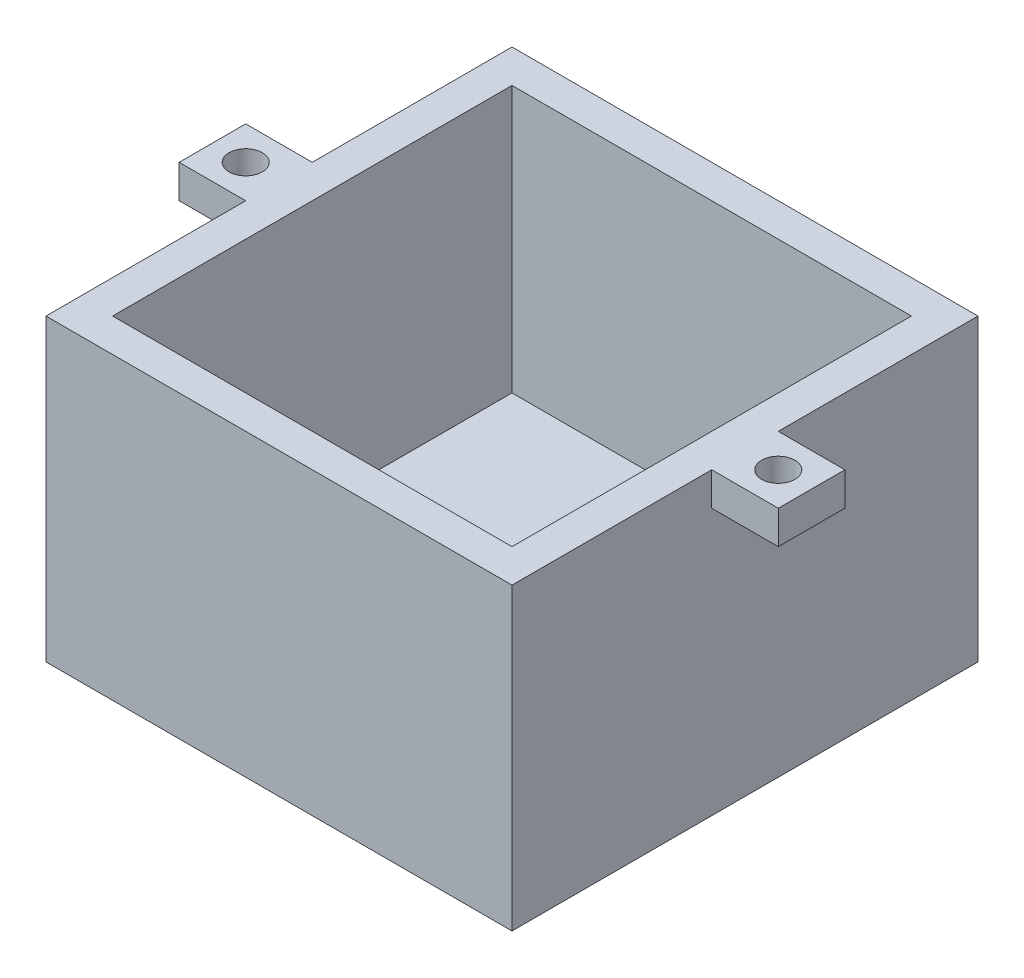
from build123d import *

# Parameters (mm, degrees)
SKETCH1_W           = 88.9
SKETCH1_H           = 88.9
SKETCH1_W_2         = 76.2
SKETCH1_H_2         = 76.2
BOSS_EXTRUDE1_DEPTH = 50.8
SKETCH2_W           = 88.9
SKETCH2_H           = 88.9
BOSS_EXTRUDE2_DEPTH = 6.35
SKETCH3_W           = 12.7
SKETCH3_H           = 12.7
BOSS_EXTRUDE3_DEPTH = 6.35
SKETCH4_R           = 3.175
CUT_EXTRUDE1_DEPTH  = 58.15


with BuildPart() as part:
    # Sketch1 → Boss-Extrude1 (new body)
    with BuildSketch(Plane(origin=(0, 0, 0), x_dir=(1, 0, 0), z_dir=(0, 1, 0))):
        with Locations((38.1, 38.1)):
            Rectangle(SKETCH1_W, SKETCH1_H)
        with Locations((38.1, 38.1)):
            Rectangle(SKETCH1_W_2, SKETCH1_H_2, mode=Mode.SUBTRACT)
    extrude(amount=BOSS_EXTRUDE1_DEPTH)

    # Sketch2 → Boss-Extrude2 (add)
    with BuildSketch(Plane.XZ):
        with Locations((38.1, -38.1)):
            Rectangle(SKETCH2_W, SKETCH2_H)
    extrude(amount=BOSS_EXTRUDE2_DEPTH)

    # Sketch3 → Boss-Extrude3 (add)
    with BuildSketch(Plane(origin=(0, 50.8, 0), x_dir=(1, 0, 0), z_dir=(0, 1, 0))):
        with Locations((88.9, 38.1)):
            Rectangle(SKETCH3_W, SKETCH3_H)
        with Locations((-12.7, 38.1)):
            Rectangle(SKETCH3_W, SKETCH3_H)
    extrude(amount=-BOSS_EXTRUDE3_DEPTH)

    # Sketch4 → Cut-Extrude1 (cut, through all)
    with BuildSketch(Plane(origin=(0, 50.8, 0), x_dir=(1, 0, 0), z_dir=(0, 1, 0))):
        with Locations((88.9, 38.1)):
            Circle(SKETCH4_R)
        with Locations((-12.7, 38.1)):
            Circle(SKETCH4_R)
    extrude(amount=-CUT_EXTRUDE1_DEPTH, mode=Mode.SUBTRACT)


solid = part.part
